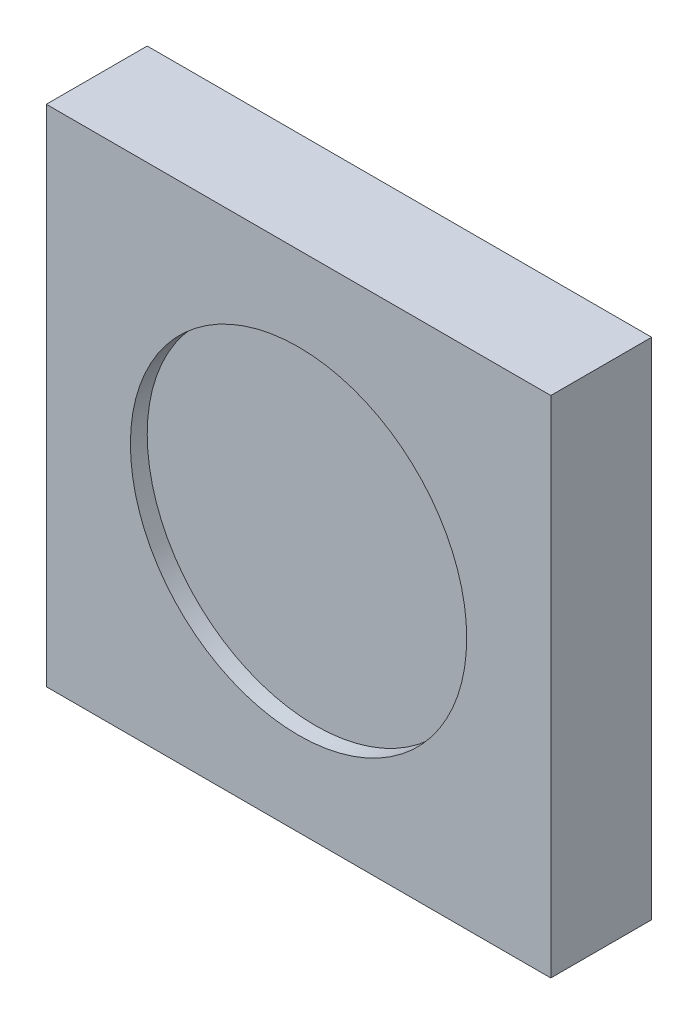
from build123d import *

# Parameters (mm, degrees)
SKETCH_1_W          = 30
SKETCH_1_H          = 30
EXTRUDE_1_DEPTH     = 6
SKETCH_2_R          = 10
CUT_EXTRUDE_1_DEPTH = 1


with BuildPart() as part:
    # 草图1 → 凸台-拉伸1 (new body)
    with BuildSketch(Plane.XY):
        with Locations((-154.212810174, 19.754563538)):
            Rectangle(SKETCH_1_W, SKETCH_1_H)
    extrude(amount=EXTRUDE_1_DEPTH)

    # 草图2 → 切除-拉伸1 (cut)
    with BuildSketch(Plane.XY.offset(6)):
        with Locations((-154.212810174, 19.754563538)):
            Circle(SKETCH_2_R)
    extrude(amount=-CUT_EXTRUDE_1_DEPTH, mode=Mode.SUBTRACT)


solid = part.part
